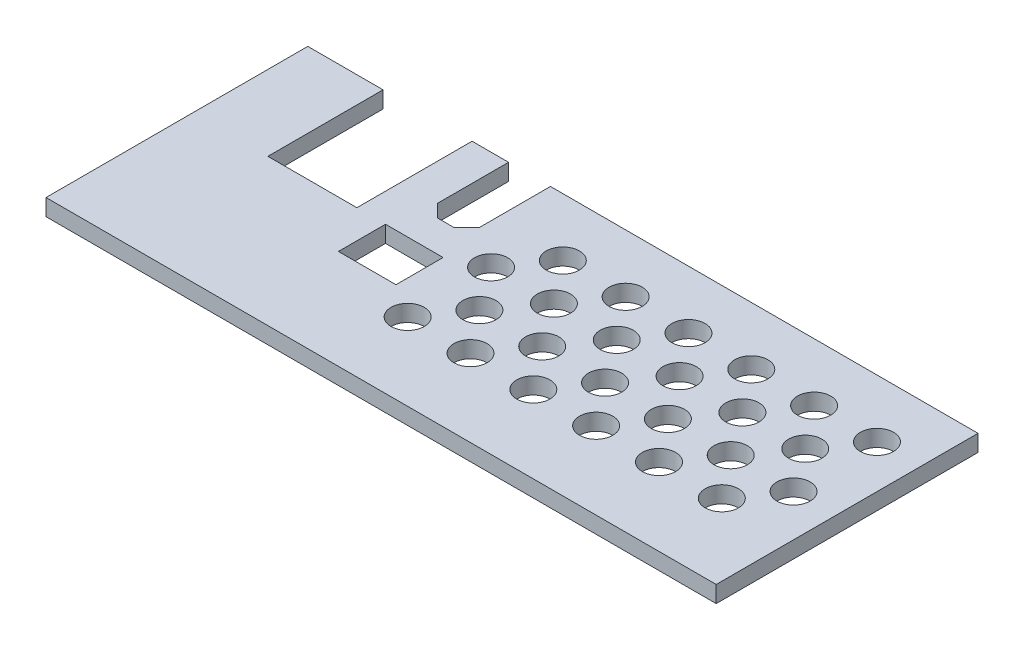
from build123d import *

# Parameters (mm, degrees)
SKETCH1_W           = 11
SKETCH1_H           = 9
BOSS_EXTRUDE1_DEPTH = 3.175
BOSS_EXTRUDE2_DEPTH = 3.175
SKETCH3_W           = 27.735440415
SKETCH3_H           = 29.716543301
BOSS_EXTRUDE3_DEPTH = 3.175
SKETCH4_R           = 3.175
CUT_EXTRUDE1_DEPTH  = 3.175


with BuildPart() as part:
    # Sketch1 → Boss-Extrude1 (new body)
    with BuildSketch(Plane(origin=(0, 0, 0), x_dir=(1, 0, 0), z_dir=(0, 1, 0))):
        Polygon((-68.253472382, 16.682663469), (-68.253472382, -31.317336531), (57.746527618, -31.317336531), (57.746527618, -18.067336531), (35.746527618, -18.067336531), (35.746527618, 5.932663469), (57.746527618, 5.932663469), (57.746527618, 16.682663469), (-21.910593359, 16.682663469), (-21.910593359, 3.082663469), (-24.310593359, 0.682663469), (-27.510593359, 0.682663469), (-29.910593359, 3.082663469), (-29.910593359, 16.682663469), (-36.877993049, 16.682663469), (-36.877993049, -5.317336531), (-53.877993049, -5.317336531), (-53.877993049, 16.682663469), align=None)
        with Locations((-25.910593359, -9.817336531)):
            Rectangle(SKETCH1_W, SKETCH1_H, mode=Mode.SUBTRACT)
    extrude(amount=BOSS_EXTRUDE1_DEPTH)

    # Sketch2 → Boss-Extrude2 (add)
    with BuildSketch(Plane(origin=(0, 3.175, 0), x_dir=(1, 0, 0), z_dir=(0, 1, 0))):
        Polygon((59.746527618, 16.682663469), (57.746527618, 16.682663469), (57.746527618, 5.932663469), (57.746527618, -18.067336531), (57.746527618, -31.317336531), (-68.253472382, -31.317336531), (-68.253472382, -33.317336531), (59.746527618, -33.317336531), align=None)
    extrude(amount=-BOSS_EXTRUDE2_DEPTH)

    # Sketch3 → Boss-Extrude3 (add)
    with BuildSketch(Plane(origin=(0, 3.175, 0), x_dir=(1, 0, 0), z_dir=(0, 1, 0))):
        with Locations((44.64848835, -4.824339336)):
            Rectangle(SKETCH3_W, SKETCH3_H)
    extrude(amount=-BOSS_EXTRUDE3_DEPTH)

    # Sketch4 → Cut-Extrude1 (cut)
    with BuildSketch(Plane(origin=(0, 3.175, 0), x_dir=(1, 0, 0), z_dir=(0, 1, 0))):
        with Locations((-8.479841083, 5.611362845)):
            Circle(SKETCH4_R)
        with Locations((3.520158917, 5.611362845)):
            Circle(SKETCH4_R)
        with Locations((15.520158917, 5.611362845)):
            Circle(SKETCH4_R)
        with Locations((27.520158917, 5.611362845)):
            Circle(SKETCH4_R)
        with Locations((39.520158917, 5.611362845)):
            Circle(SKETCH4_R)
        with Locations((51.520158917, 5.611362845)):
            Circle(SKETCH4_R)
        with Locations((-14.20477293, -2.36159985)):
            Circle(SKETCH4_R)
        with Locations((-2.20477293, -2.36159985)):
            Circle(SKETCH4_R)
        with Locations((9.79522707, -2.36159985)):
            Circle(SKETCH4_R)
        with Locations((21.79522707, -2.36159985)):
            Circle(SKETCH4_R)
        with Locations((33.79522707, -2.36159985)):
            Circle(SKETCH4_R)
        with Locations((45.79522707, -2.36159985)):
            Circle(SKETCH4_R)
        with Locations((-8.244355205, -10.556666731)):
            Circle(SKETCH4_R)
        with Locations((3.755644795, -10.556666731)):
            Circle(SKETCH4_R)
        with Locations((15.755644795, -10.556666731)):
            Circle(SKETCH4_R)
        with Locations((27.755644795, -10.556666731)):
            Circle(SKETCH4_R)
        with Locations((39.755644795, -10.556666731)):
            Circle(SKETCH4_R)
        with Locations((51.755644795, -10.556666731)):
            Circle(SKETCH4_R)
        with Locations((-13.969287051, -18.529629426)):
            Circle(SKETCH4_R)
        with Locations((-1.969287051, -18.529629426)):
            Circle(SKETCH4_R)
        with Locations((10.030712949, -18.529629426)):
            Circle(SKETCH4_R)
        with Locations((22.030712949, -18.529629426)):
            Circle(SKETCH4_R)
        with Locations((34.030712949, -18.529629426)):
            Circle(SKETCH4_R)
        with Locations((46.030712949, -18.529629426)):
            Circle(SKETCH4_R)
    extrude(amount=-CUT_EXTRUDE1_DEPTH, mode=Mode.SUBTRACT)


solid = part.part
